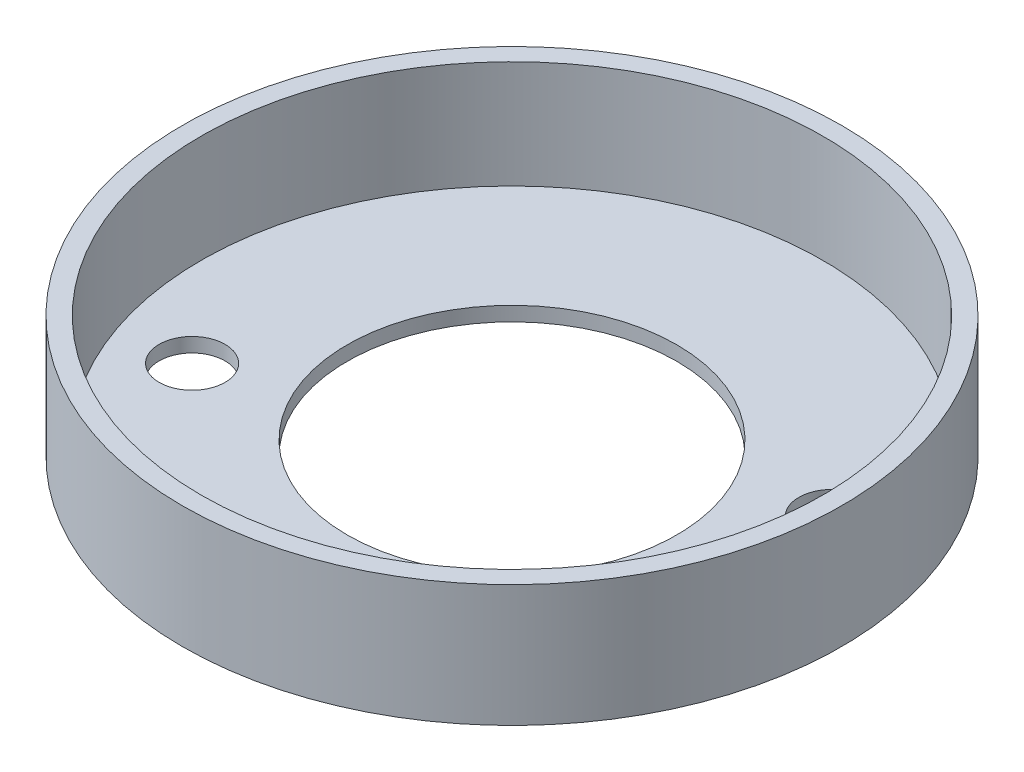
from build123d import *

# Parameters (mm, degrees)
SKETCH1_R           = 35
SKETCH1_R_2         = 17.5
SKETCH1_R_3         = 3.5
BOSS_EXTRUDE1_DEPTH = 12.954
SKETCH2_R           = 33.02
CUT_EXTRUDE1_DEPTH  = 11.43


with BuildPart() as part:
    # Sketch1 → Boss-Extrude1 (new body)
    with BuildSketch(Plane(origin=(0, 0, 0), x_dir=(1, 0, 0), z_dir=(0, 1, 0))):
        Circle(SKETCH1_R)
        Circle(SKETCH1_R_2, mode=Mode.SUBTRACT)
        with Locations((-24.023795501, -9.950801949)):
            Circle(SKETCH1_R_3, mode=Mode.SUBTRACT)
        with Locations((24.018239985, 9.948012748)):
            Circle(SKETCH1_R_3, mode=Mode.SUBTRACT)
        with Locations((9.950974523, -24.02421215)):
            Circle(SKETCH1_R_3, mode=Mode.SUBTRACT)
    extrude(amount=BOSS_EXTRUDE1_DEPTH)

    # Sketch2 → Cut-Extrude1 (cut)
    with BuildSketch(Plane(origin=(0, 12.954, 0), x_dir=(1, 0, 0), z_dir=(0, 1, 0))):
        Circle(SKETCH2_R)
    extrude(amount=-CUT_EXTRUDE1_DEPTH, mode=Mode.SUBTRACT)


solid = part.part
